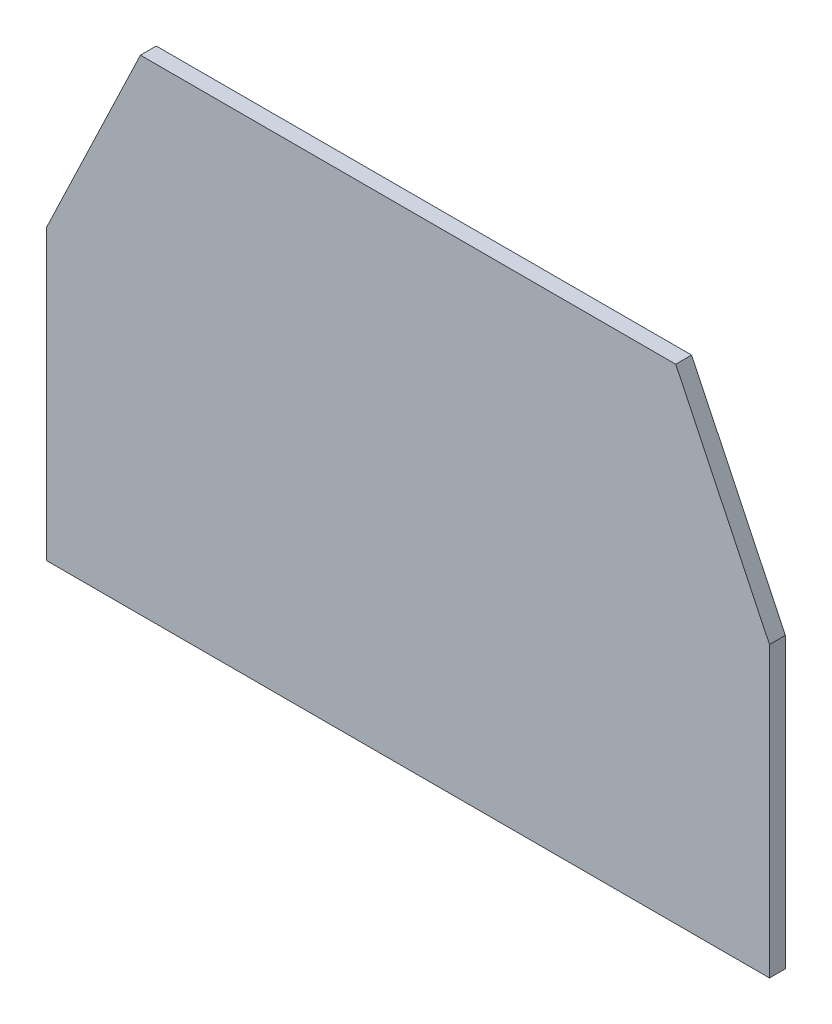
from build123d import *

# Parameters (mm, degrees)
AUFSATZ_LINEAR_AUSTRAGEN1_DEPTH = 15


with BuildPart() as part:
    # Skizze1 → Aufsatz-Linear austragen1 (new body)
    with BuildSketch(Plane.XY):
        Polygon((341.858259494, -194.367647059), (-341.858259494, -194.367647059), (-341.858259494, 78.794563683), (-253.156995608, 264.02367356), (253.156995608, 264.02367356), (341.858259494, 78.794563683), align=None)
    extrude(amount=AUFSATZ_LINEAR_AUSTRAGEN1_DEPTH)


solid = part.part
